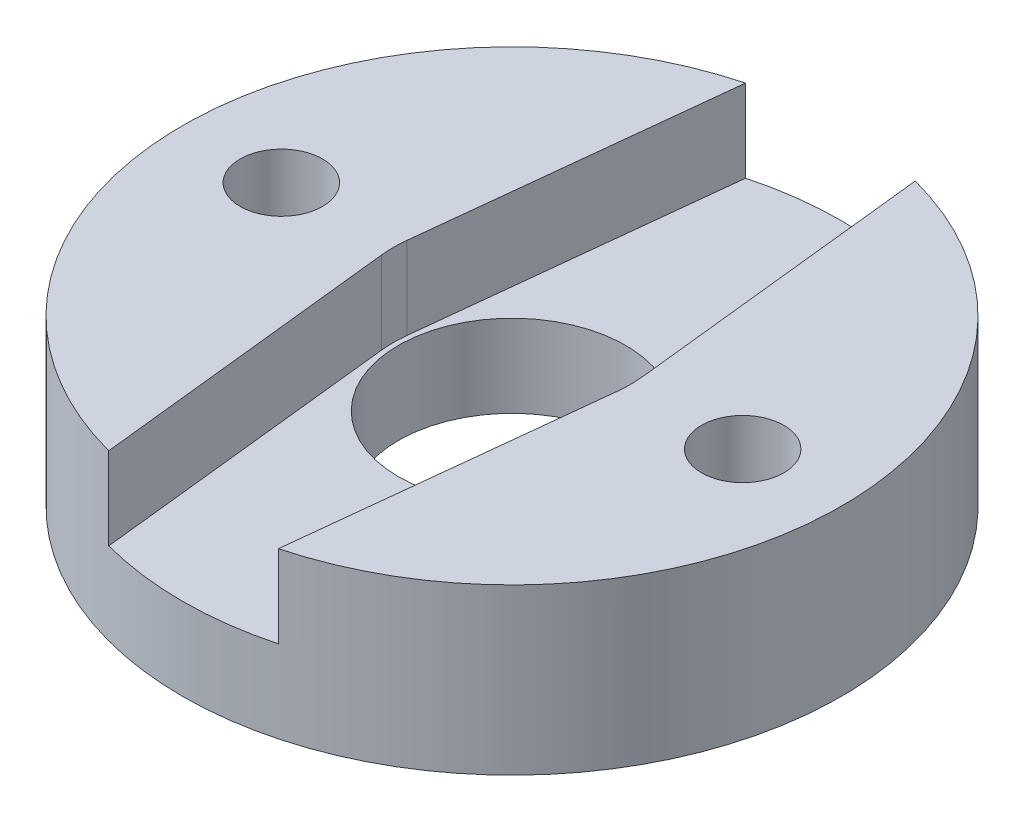
from build123d import *

# Parameters (mm, degrees)
SKETCH1_R                       = 10
BOSS_EXTRUDE1_DEPTH             = 5
TAP_DRILL_FOR_M3X0_5_TAP1_D     = 2.5
TAP_DRILL_FOR_M3X0_5_TAP1_DEPTH = 38.1
CIRPATTERN1_COUNT               = 4
F_14_0_182_DIAMETER_HOLE1_D     = 6.899999916
CUT_EXTRUDE3_DEPTH              = 2.5


with BuildPart() as part:
    # Sketch1 → Boss-Extrude1 (new body)
    with BuildSketch(Plane(origin=(0, 0, 0), x_dir=(1, 0, 0), z_dir=(0, 1, 0))):
        Circle(SKETCH1_R)
    extrude(amount=BOSS_EXTRUDE1_DEPTH)

    # Tap Drill for M3x0.5 Tap1
    with Locations(Plane(origin=(0, 5, 0), x_dir=(1, 0, 0), z_dir=(0, 1, 0))):
        with Locations((7, 0)):
            tap_drill_for_m3x0_5_tap1 = Hole(TAP_DRILL_FOR_M3X0_5_TAP1_D / 2, depth=TAP_DRILL_FOR_M3X0_5_TAP1_DEPTH)

    # CirPattern1: Tap Drill for M3x0.5 Tap1 ×4 about axis, 2 skipped
    cirpattern1_axis = Axis((0, 5, 0), (0, -1, 0))
    add([tap_drill_for_m3x0_5_tap1.rotate(cirpattern1_axis, i * 360 / CIRPATTERN1_COUNT) for i in range(1, CIRPATTERN1_COUNT) if i not in (1, 3)], mode=Mode.SUBTRACT)

    # #14 (0.182) Diameter Hole1 (through all)
    with Locations(Plane(origin=(0, 5, 0), x_dir=(1, 0, 0), z_dir=(0, 1, 0))):
        with Locations((0, 0)):
            Hole(F_14_0_182_DIAMETER_HOLE1_D / 2)

    # Sketch10 → Cut-Extrude3 (cut)
    with BuildSketch(Plane(origin=(0, 5, 0), x_dir=(1, 0, 0), z_dir=(0, 1, 0))):
        with BuildLine():
            Line((-3.57904225, 0.387887324), (-2.057949293, 14.423035211))
            ThreePointArc((-2.057949293, 14.423035211), (0, 16.27), (2.057949293, 14.423035211))
            Line((2.057949293, 14.423035211), (3.57904225, 0.387887324))
            ThreePointArc((3.57904225, 0.387887324), (3.6, 0), (3.57904225, -0.387887324))
            Line((3.57904225, -0.387887324), (2.057949293, -14.423035211))
            ThreePointArc((2.057949293, -14.423035211), (0, -16.27), (-2.057949293, -14.423035211))
            Line((-2.057949293, -14.423035211), (-3.57904225, -0.387887324))
            ThreePointArc((-3.57904225, -0.387887324), (-3.6, 0), (-3.57904225, 0.387887324))
        make_face()
    extrude(amount=-CUT_EXTRUDE3_DEPTH, mode=Mode.SUBTRACT)


solid = part.part
